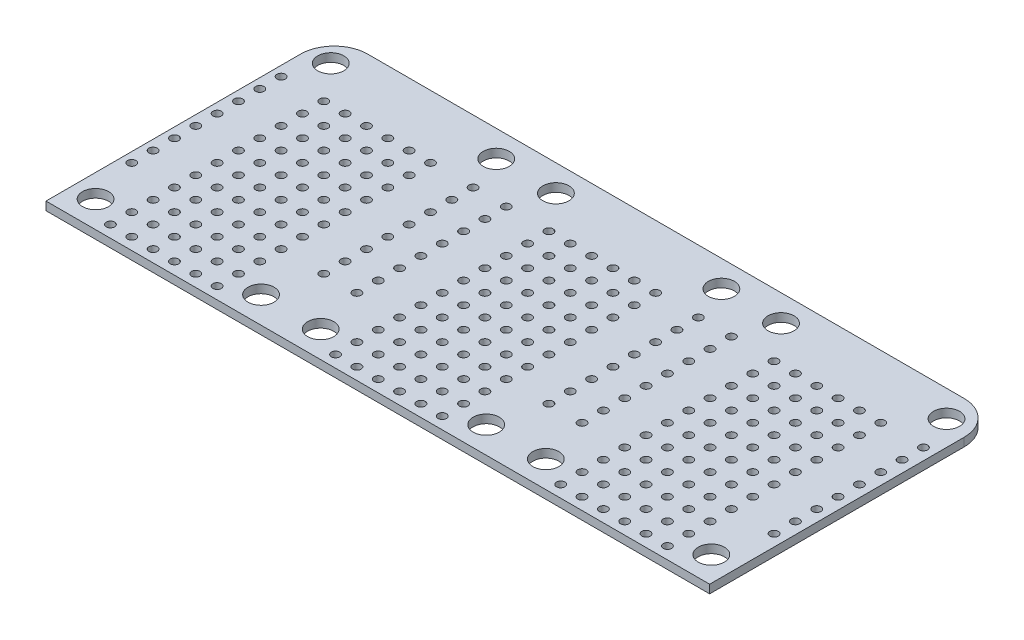
from build123d import *

# Parameters (mm, degrees)
BOARD_W             = 79
BOARD_H             = 34.3
BOSS_EXTRUDE1_DEPTH = 1
HOLES_R             = 1.55
HOLES_R_2           = 0.5
CUT_EXTRUDE1_DEPTH  = 87.130656563
LPATTERN1_COUNT     = 3
LPATTERN1_PITCH     = 26.8
FILLET1_R           = 4


with BuildPart() as part:
    # board → Boss-Extrude1 (new body)
    with BuildSketch(Plane(origin=(0, 0, 0), x_dir=(1, 0, 0), z_dir=(0, 1, 0))):
        with Locations((39.5, 17.15)):
            Rectangle(BOARD_W, BOARD_H)
    extrude(amount=BOSS_EXTRUDE1_DEPTH)

    # holes → Cut-Extrude1 (cut, through all)
    with BuildSketch(Plane(origin=(0, 0, 0), x_dir=(1, 0, 0), z_dir=(0, 1, 0))):
        with Locations((2.75, 31.15)):
            Circle(HOLES_R)
        with Locations((22.45, 31.15)):
            Circle(HOLES_R)
        with Locations((22.45, 3.15)):
            Circle(HOLES_R)
        with Locations((2.75, 3.15)):
            Circle(HOLES_R)
        with Locations((1.17, 26.82)):
            Circle(HOLES_R_2)
        with Locations((24.03, 26.82)):
            Circle(HOLES_R_2)
        with Locations((6.25, 26.82)):
            Circle(HOLES_R_2)
        with Locations((1.17, 24.28)):
            Circle(HOLES_R_2)
        with Locations((24.03, 24.28)):
            Circle(HOLES_R_2)
        with Locations((1.17, 21.74)):
            Circle(HOLES_R_2)
        with Locations((24.03, 21.74)):
            Circle(HOLES_R_2)
        with Locations((1.17, 19.2)):
            Circle(HOLES_R_2)
        with Locations((24.03, 19.2)):
            Circle(HOLES_R_2)
        with Locations((1.17, 16.66)):
            Circle(HOLES_R_2)
        with Locations((24.03, 16.66)):
            Circle(HOLES_R_2)
        with Locations((1.17, 14.12)):
            Circle(HOLES_R_2)
        with Locations((24.03, 14.12)):
            Circle(HOLES_R_2)
        with Locations((1.17, 11.58)):
            Circle(HOLES_R_2)
        with Locations((24.03, 11.58)):
            Circle(HOLES_R_2)
        with Locations((1.17, 9.04)):
            Circle(HOLES_R_2)
        with Locations((24.03, 9.04)):
            Circle(HOLES_R_2)
        with Locations((6.25, 24.28)):
            Circle(HOLES_R_2)
        with Locations((6.25, 21.74)):
            Circle(HOLES_R_2)
        with Locations((6.25, 19.2)):
            Circle(HOLES_R_2)
        with Locations((6.25, 16.66)):
            Circle(HOLES_R_2)
        with Locations((6.25, 14.12)):
            Circle(HOLES_R_2)
        with Locations((6.25, 11.58)):
            Circle(HOLES_R_2)
        with Locations((6.25, 9.04)):
            Circle(HOLES_R_2)
        with Locations((6.25, 6.5)):
            Circle(HOLES_R_2)
        with Locations((6.25, 3.96)):
            Circle(HOLES_R_2)
        with Locations((6.25, 1.42)):
            Circle(HOLES_R_2)
        with Locations((8.79, 24.28)):
            Circle(HOLES_R_2)
        with Locations((8.79, 21.74)):
            Circle(HOLES_R_2)
        with Locations((8.79, 19.2)):
            Circle(HOLES_R_2)
        with Locations((8.79, 16.66)):
            Circle(HOLES_R_2)
        with Locations((8.79, 14.12)):
            Circle(HOLES_R_2)
        with Locations((8.79, 11.58)):
            Circle(HOLES_R_2)
        with Locations((8.79, 9.04)):
            Circle(HOLES_R_2)
        with Locations((8.79, 6.5)):
            Circle(HOLES_R_2)
        with Locations((8.79, 3.96)):
            Circle(HOLES_R_2)
        with Locations((8.79, 1.42)):
            Circle(HOLES_R_2)
        with Locations((11.33, 24.28)):
            Circle(HOLES_R_2)
        with Locations((11.33, 21.74)):
            Circle(HOLES_R_2)
        with Locations((11.33, 19.2)):
            Circle(HOLES_R_2)
        with Locations((11.33, 16.66)):
            Circle(HOLES_R_2)
        with Locations((11.33, 14.12)):
            Circle(HOLES_R_2)
        with Locations((11.33, 11.58)):
            Circle(HOLES_R_2)
        with Locations((11.33, 9.04)):
            Circle(HOLES_R_2)
        with Locations((11.33, 6.5)):
            Circle(HOLES_R_2)
        with Locations((11.33, 3.96)):
            Circle(HOLES_R_2)
        with Locations((11.33, 1.42)):
            Circle(HOLES_R_2)
        with Locations((13.87, 24.28)):
            Circle(HOLES_R_2)
        with Locations((13.87, 21.74)):
            Circle(HOLES_R_2)
        with Locations((13.87, 19.2)):
            Circle(HOLES_R_2)
        with Locations((13.87, 16.66)):
            Circle(HOLES_R_2)
        with Locations((13.87, 14.12)):
            Circle(HOLES_R_2)
        with Locations((13.87, 11.58)):
            Circle(HOLES_R_2)
        with Locations((13.87, 9.04)):
            Circle(HOLES_R_2)
        with Locations((13.87, 6.5)):
            Circle(HOLES_R_2)
        with Locations((13.87, 3.96)):
            Circle(HOLES_R_2)
        with Locations((13.87, 1.42)):
            Circle(HOLES_R_2)
        with Locations((16.41, 24.28)):
            Circle(HOLES_R_2)
        with Locations((16.41, 21.74)):
            Circle(HOLES_R_2)
        with Locations((16.41, 19.2)):
            Circle(HOLES_R_2)
        with Locations((16.41, 16.66)):
            Circle(HOLES_R_2)
        with Locations((16.41, 14.12)):
            Circle(HOLES_R_2)
        with Locations((16.41, 11.58)):
            Circle(HOLES_R_2)
        with Locations((16.41, 9.04)):
            Circle(HOLES_R_2)
        with Locations((16.41, 6.5)):
            Circle(HOLES_R_2)
        with Locations((16.41, 3.96)):
            Circle(HOLES_R_2)
        with Locations((16.41, 1.42)):
            Circle(HOLES_R_2)
        with Locations((18.95, 24.28)):
            Circle(HOLES_R_2)
        with Locations((18.95, 21.74)):
            Circle(HOLES_R_2)
        with Locations((18.95, 19.2)):
            Circle(HOLES_R_2)
        with Locations((18.95, 16.66)):
            Circle(HOLES_R_2)
        with Locations((18.95, 14.12)):
            Circle(HOLES_R_2)
        with Locations((18.95, 11.58)):
            Circle(HOLES_R_2)
        with Locations((18.95, 9.04)):
            Circle(HOLES_R_2)
        with Locations((18.95, 6.5)):
            Circle(HOLES_R_2)
        with Locations((18.95, 3.96)):
            Circle(HOLES_R_2)
        with Locations((18.95, 1.42)):
            Circle(HOLES_R_2)
        with Locations((8.79, 26.82)):
            Circle(HOLES_R_2)
        with Locations((11.33, 26.82)):
            Circle(HOLES_R_2)
        with Locations((13.87, 26.82)):
            Circle(HOLES_R_2)
        with Locations((16.41, 26.82)):
            Circle(HOLES_R_2)
        with Locations((18.95, 26.82)):
            Circle(HOLES_R_2)
    cut_extrude1 = extrude(amount=CUT_EXTRUDE1_DEPTH, mode=Mode.SUBTRACT)

    # LPattern1: Cut-Extrude1 ×3
    with Locations(*[(i * LPATTERN1_PITCH, 0, 0) for i in range(1, LPATTERN1_COUNT)]):
        add(cut_extrude1, mode=Mode.SUBTRACT)

    # Fillet1
    fillet1_edges = [part.edges().sort_by_distance(p)[0] for p in [
        (79, 0.5, -34.3),
        (0, 0.5, -34.3),
    ]]
    fillet(fillet1_edges, radius=FILLET1_R)


solid = part.part
